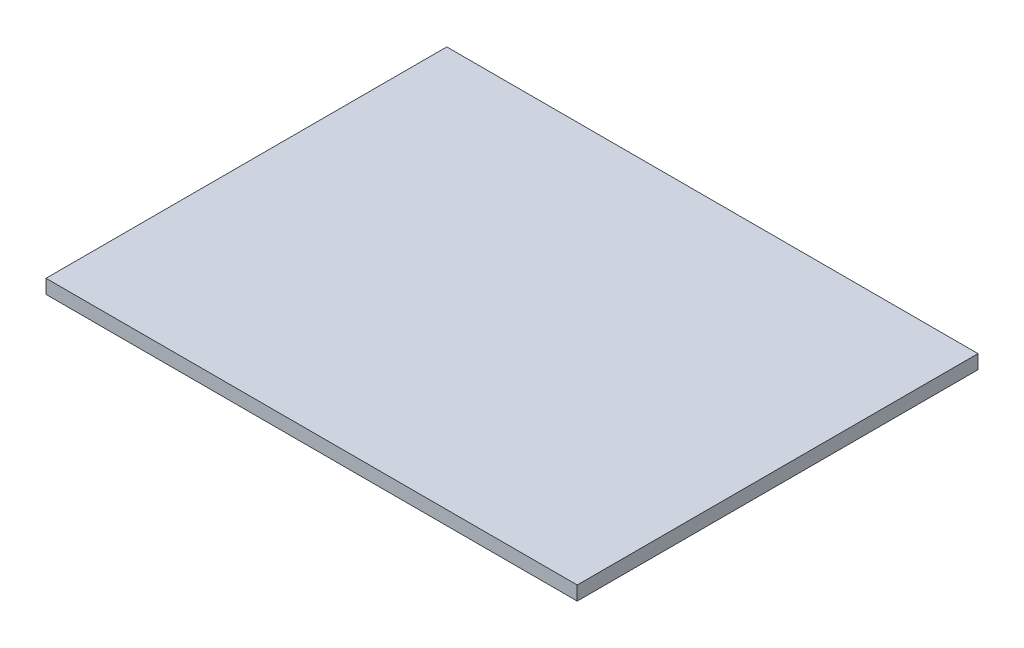
from build123d import *

# Parameters (mm, degrees)
SKETCH1_W           = 180.975
SKETCH1_H           = 136.525
BOSS_EXTRUDE1_DEPTH = 4.7625


with BuildPart() as part:
    # Sketch1 → Boss-Extrude1 (new body)
    with BuildSketch(Plane(origin=(0, 0, 0), x_dir=(1, 0, 0), z_dir=(0, 1, 0))):
        with Locations((90.4875, -68.2625)):
            Rectangle(SKETCH1_W, SKETCH1_H)
    extrude(amount=BOSS_EXTRUDE1_DEPTH)


solid = part.part
